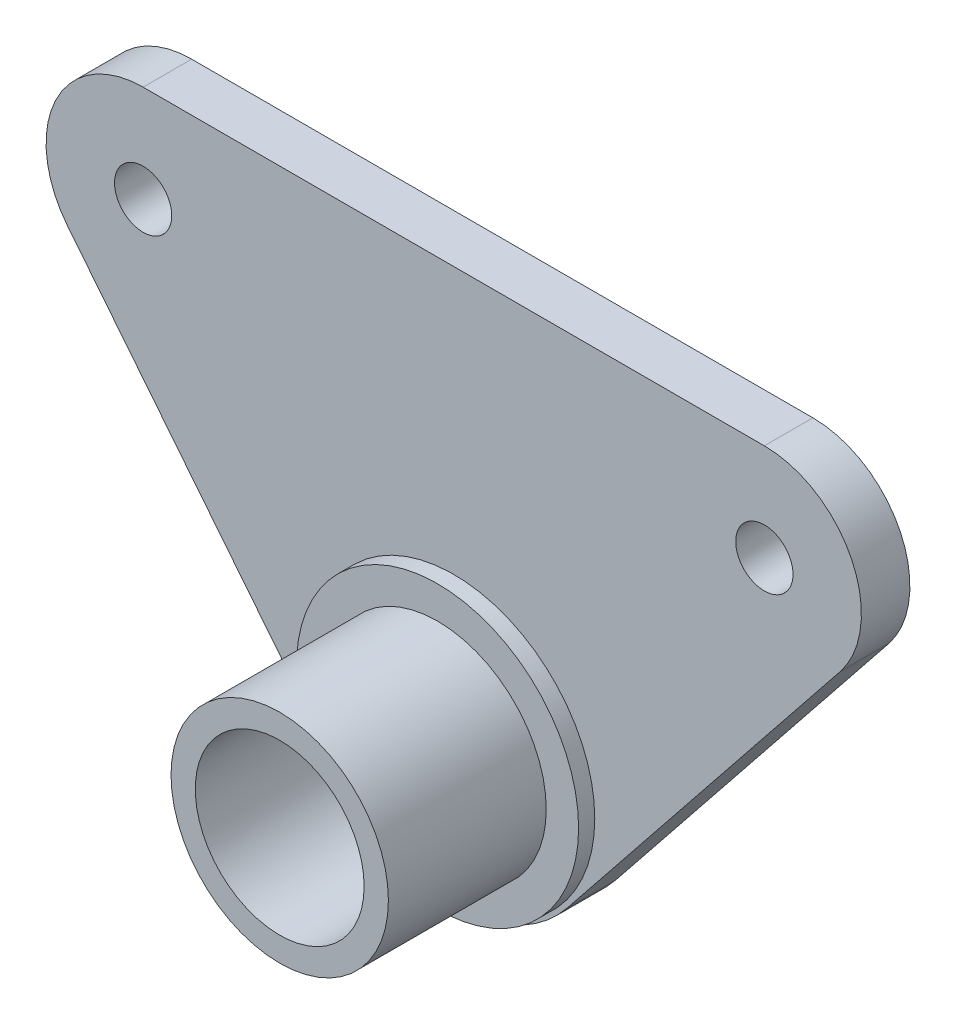
from build123d import *

# Parameters (mm, degrees)
BOSS_EXTRUDE1_DEPTH      = 3.81
BOSS_EXTRUDE2_START      = -3.81
SKETCH2_R                = 8.5344
SKETCH2_R_2              = 6.6294
BOSS_EXTRUDE2_DEPTH      = 17.4752
SKETCH4_R                = 6.6294
CUT_EXTRUDE2_DEPTH       = 4.81
SKETCH5_R                = 11.0744
SKETCH5_R_2              = 8.5344
BOSS_EXTRUDE3_DEPTH      = 1.27
BOSS_EXTRUDE3_DEPTH_BACK = 3.81
F_8_CLEARANCE_HOLE1_D    = 4.4958


with BuildPart() as part:
    # Sketch1 → Boss-Extrude1 (new body)
    with BuildSketch(Plane.XY):
        with BuildLine():
            Line((-24.39, 32.01), (24.39, 32.01))
            ThreePointArc((24.39, 32.01), (31.257886274, 27.690990477), (30.340348343, 19.629983761))
            Line((30.340348343, 19.629983761), (8.925522514, -7.140024359))
            ThreePointArc((8.925522514, -7.140024359), (0, -11.43), (-8.925522514, -7.140024359))
            Line((-8.925522514, -7.140024359), (-30.340348343, 19.629983761))
            ThreePointArc((-30.340348343, 19.629983761), (-31.257886274, 27.690990477), (-24.39, 32.01))
        make_face()
    extrude(amount=BOSS_EXTRUDE1_DEPTH)

    # Sketch2 → Boss-Extrude2 (add)
    with BuildSketch(Plane.XY.offset(3.81).offset(BOSS_EXTRUDE2_START)):
        Circle(SKETCH2_R)
        Circle(SKETCH2_R_2, mode=Mode.SUBTRACT)
    extrude(amount=BOSS_EXTRUDE2_DEPTH)

    # Sketch4 → Cut-Extrude2 (cut, through all)
    with BuildSketch(Plane.XY.offset(3.81)):
        Circle(SKETCH4_R)
    extrude(amount=-CUT_EXTRUDE2_DEPTH, mode=Mode.SUBTRACT)

    # Sketch5 → Boss-Extrude3 (add, two sides)
    with BuildSketch(Plane.XY.offset(3.81)) as boss_extrude3_sk:
        Circle(SKETCH5_R)
        Circle(SKETCH5_R_2, mode=Mode.SUBTRACT)
    extrude(amount=BOSS_EXTRUDE3_DEPTH)
    extrude(boss_extrude3_sk.sketch, amount=-BOSS_EXTRUDE3_DEPTH_BACK)

    # #8 Clearance Hole1 (through all)
    with Locations(Plane.XY.offset(3.81)):
        with Locations((-24.39, 24.39), (24.39, 24.39)):
            Hole(F_8_CLEARANCE_HOLE1_D / 2)


solid = part.part
